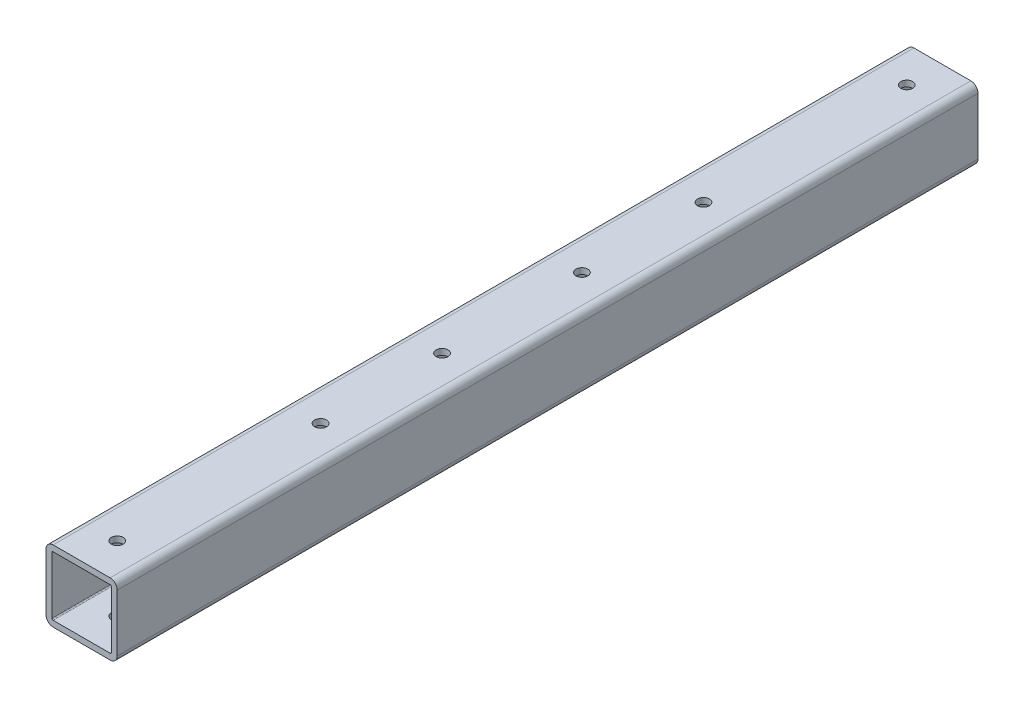
from build123d import *

# Parameters (mm, degrees)
SKETCH1_W               = 38.1
SKETCH1_H               = 38.1
SKETCH1_W_2             = 31.75
SKETCH1_H_2             = 31.75
BOSS_EXTRUDE1_DEPTH     = 230.1875
FILLET1_R               = 3.81
FILLET2_R               = 0.635
SKETCH2_R               = 3.175
CUT_EXTRUDE1_DEPTH      = 20.05
CUT_EXTRUDE1_DEPTH_BACK = 20.05


with BuildPart() as part:
    # Sketch1 → Boss-Extrude1 (new body, symmetric)
    with BuildSketch(Plane.XY):
        Rectangle(SKETCH1_W, SKETCH1_H)
        Rectangle(SKETCH1_W_2, SKETCH1_H_2, mode=Mode.SUBTRACT)
    extrude(amount=BOSS_EXTRUDE1_DEPTH, both=True)

    # Fillet1
    fillet1_edges = [part.edges().sort_by_distance(p)[0] for p in [
        (19.05, -19.05, 0),
        (-19.05, -19.05, 0),
        (-19.05, 19.05, 0),
        (19.05, 19.05, 0),
    ]]
    fillet(fillet1_edges, radius=FILLET1_R)

    # Fillet2
    fillet2_edges = [part.edges().sort_by_distance(p)[0] for p in [
        (15.875, 15.875, 0),
        (-15.875, 15.875, 0),
        (-15.875, -15.875, 0),
        (15.875, -15.875, 0),
    ]]
    fillet(fillet2_edges, radius=FILLET2_R)

    # Sketch2 → Cut-Extrude1 (cut, two sides)
    with BuildSketch(Plane(origin=(0, 0, 0), x_dir=(1, 0, 0), z_dir=(0, 1, 0))) as cut_extrude1_sk:
        with Locations((0, -211.1375)):
            Circle(SKETCH2_R)
        with Locations((0, -102.4)):
            Circle(SKETCH2_R)
        with Locations((0, -37.4)):
            Circle(SKETCH2_R)
        with Locations((0, 37.4)):
            Circle(SKETCH2_R)
        with Locations((0, 102.4)):
            Circle(SKETCH2_R)
        with Locations((0, 211.1375)):
            Circle(SKETCH2_R)
    extrude(amount=CUT_EXTRUDE1_DEPTH, mode=Mode.SUBTRACT)
    extrude(cut_extrude1_sk.sketch, amount=-CUT_EXTRUDE1_DEPTH_BACK, mode=Mode.SUBTRACT)


solid = part.part
